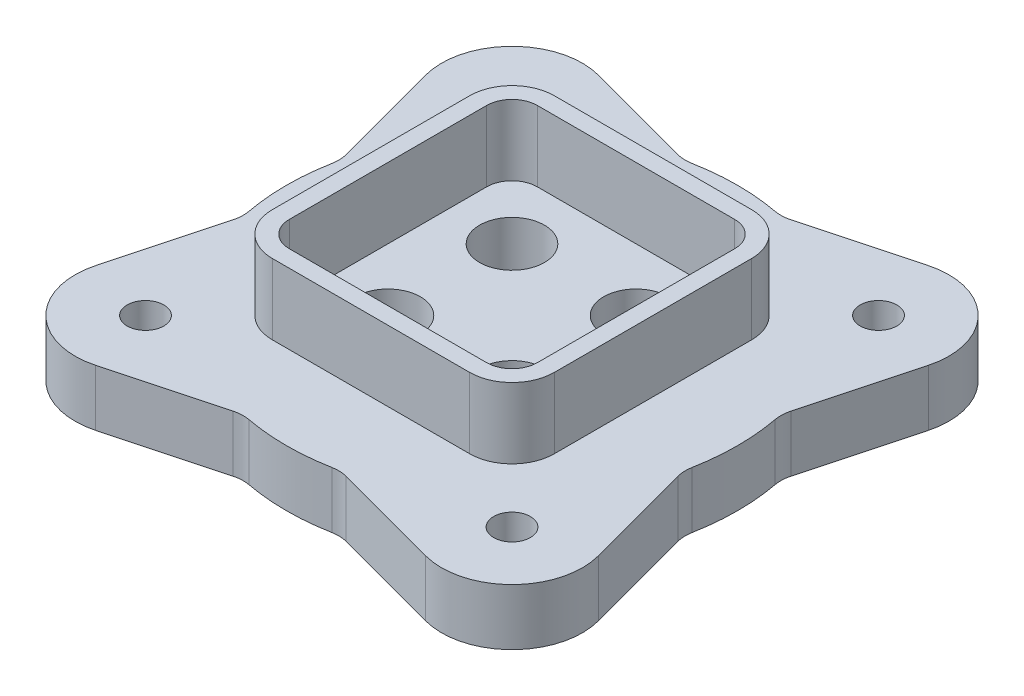
from build123d import *

# Parameters (mm, degrees)
SKETCH1_R           = 6.5
BOSS_EXTRUDE1_DEPTH = 20
SKETCH2_R           = 11.5
CUT_EXTRUDE1_DEPTH  = 129.840987267
BOSS_EXTRUDE2_DEPTH = 25
SKETCH3_R           = 72.5
SKETCH3_R_2         = 52.5
CUT_EXTRUDE2_DEPTH  = 3
FILLET2_R           = 12


with BuildPart() as part:
    # Sketch1 → Boss-Extrude1 (new body)
    with BuildSketch(Plane(origin=(0, 0, 0), x_dir=(1, 0, 0), z_dir=(0, 1, 0))):
        with BuildLine():
            Line((-89.148145657, 58.529523872), (-78.104184034, 17.312897978))
            ThreePointArc((-78.104184034, 17.312897978), (-80, 0), (-78.104184034, -17.312897978))
            Line((-78.104184034, -17.312897978), (-89.148145657, -58.529523872))
            ThreePointArc((-89.148145657, -58.529523872), (-82.67766953, -82.67766953), (-58.529523872, -89.148145657))
            Line((-58.529523872, -89.148145657), (-17.312897978, -78.104184034))
            ThreePointArc((-17.312897978, -78.104184034), (0, -80), (17.312897978, -78.104184034))
            Line((17.312897978, -78.104184034), (58.529523872, -89.148145657))
            ThreePointArc((58.529523872, -89.148145657), (82.67766953, -82.67766953), (89.148145657, -58.529523872))
            Line((89.148145657, -58.529523872), (78.104184034, -17.312897978))
            ThreePointArc((78.104184034, -17.312897978), (80, 0), (78.104184034, 17.312897978))
            Line((78.104184034, 17.312897978), (89.148145657, 58.529523872))
            ThreePointArc((89.148145657, 58.529523872), (82.67766953, 82.67766953), (58.529523872, 89.148145657))
            Line((58.529523872, 89.148145657), (17.312897978, 78.104184034))
            ThreePointArc((17.312897978, 78.104184034), (0, 80), (-17.312897978, 78.104184034))
            Line((-17.312897978, 78.104184034), (-58.529523872, 89.148145657))
            ThreePointArc((-58.529523872, 89.148145657), (-82.67766953, 82.67766953), (-89.148145657, 58.529523872))
        make_face()
        with Locations((-65, 65)):
            Circle(SKETCH1_R, mode=Mode.SUBTRACT)
        with Locations((65, 65)):
            Circle(SKETCH1_R, mode=Mode.SUBTRACT)
        with Locations((65, -65)):
            Circle(SKETCH1_R, mode=Mode.SUBTRACT)
        with Locations((-65, -65)):
            Circle(SKETCH1_R, mode=Mode.SUBTRACT)
    extrude(amount=BOSS_EXTRUDE1_DEPTH)

    # Sketch2 → Cut-Extrude1 (cut, through all)
    with BuildSketch(Plane(origin=(0, 20, 0), x_dir=(1, 0, 0), z_dir=(0, 1, 0))):
        with Locations((-22, 22)):
            Circle(SKETCH2_R)
        with Locations((22, 22)):
            Circle(SKETCH2_R)
        with Locations((22, -22)):
            Circle(SKETCH2_R)
        with Locations((-22, -22)):
            Circle(SKETCH2_R)
    extrude(amount=-CUT_EXTRUDE1_DEPTH, mode=Mode.SUBTRACT)

    # Sketch2_3 → Boss-Extrude2 (add)
    with BuildSketch(Plane(origin=(0, 20, 0), x_dir=(1, 0, 0), z_dir=(0, 1, 0))):
        with BuildLine():
            ThreePointArc((-50, -35), (-45.606601718, -45.606601718), (-35, -50))
            Line((-35, -50), (35, -50))
            ThreePointArc((35, -50), (45.606601718, -45.606601718), (50, -35))
            Line((50, -35), (50, 35))
            ThreePointArc((50, 35), (45.606601718, 45.606601718), (35, 50))
            Line((35, 50), (-35, 50))
            ThreePointArc((-35, 50), (-45.606601718, 45.606601718), (-50, 35))
            Line((-50, 35), (-50, -35))
        make_face()
        with BuildLine():
            ThreePointArc((-35, -44), (-41.363961031, -41.363961031), (-44, -35))
            Line((-44, -35), (-44, 35))
            ThreePointArc((-44, 35), (-41.363961031, 41.363961031), (-35, 44))
            Line((-35, 44), (35, 44))
            ThreePointArc((35, 44), (41.363961031, 41.363961031), (44, 35))
            Line((44, 35), (44, -35))
            ThreePointArc((44, -35), (41.363961031, -41.363961031), (35, -44))
            Line((35, -44), (-35, -44))
        make_face(mode=Mode.SUBTRACT)
    extrude(amount=BOSS_EXTRUDE2_DEPTH)

    # Sketch3 → Cut-Extrude2 (cut)
    with BuildSketch(Plane.XZ):
        Circle(SKETCH3_R)
        Circle(SKETCH3_R_2, mode=Mode.SUBTRACT)
    extrude(amount=-CUT_EXTRUDE2_DEPTH, mode=Mode.SUBTRACT)

    # Fillet2
    fillet2_edges = [part.edges().sort_by_distance(p)[0] for p in [
        (-17.312897978, 10, -78.104184034),
        (17.312897978, 10, -78.104184034),
        (17.312897978, 10, 78.104184034),
        (-17.312897978, 10, 78.104184034),
        (-78.104184034, 10, 17.312897978),
        (-78.104184034, 10, -17.312897978),
        (78.104184034, 10, -17.312897978),
        (78.104184034, 10, 17.312897978),
    ]]
    fillet(fillet2_edges, radius=FILLET2_R)


solid = part.part
